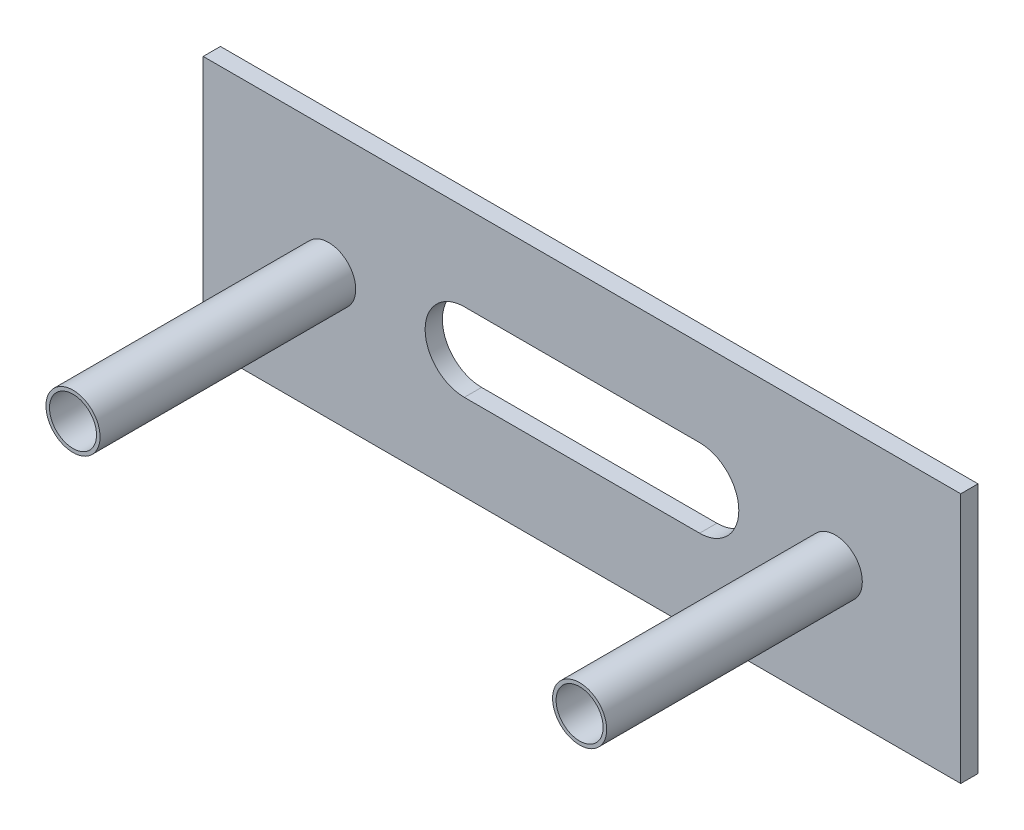
from build123d import *

# Parameters (mm, degrees)
ESQUISSE1_W             = 96.6
ESQUISSE1_H             = 32
BOSS_EXTRU_1_DEPTH      = 2.2
ESQUISSE6_R             = 3.45
BOSS_EXTRU_2_DEPTH      = 32.6
ESQUISSE7_R             = 3
ENL_V_MAT_EXTRU_1_DEPTH = 35.8


with BuildPart() as part:
    # Esquisse1 → Boss.-Extru.1 (new body)
    with BuildSketch(Plane.XY):
        with Locations((0.671156739, 2.259938231)):
            Rectangle(ESQUISSE1_W, ESQUISSE1_H)
    extrude(amount=BOSS_EXTRU_1_DEPTH)

    # Esquisse6 → Boss.-Extru.2 (add)
    with BuildSketch(Plane.XY.offset(2.2)):
        with Locations((-31.628843261, 2.259938231)):
            Circle(ESQUISSE6_R)
        with Locations((32.971156739, 2.259938231)):
            Circle(ESQUISSE6_R)
    extrude(amount=BOSS_EXTRU_2_DEPTH)

    # Esquisse7 → Enlèv. mat.-Extru.1 (cut, through all)
    with BuildSketch(Plane.XY.offset(34.8)):
        with Locations((-31.628843261, 2.259938231)):
            Circle(ESQUISSE7_R)
        with Locations((32.971156739, 2.259938231)):
            Circle(ESQUISSE7_R)
        with BuildLine():
            Line((-14.328843261, 7.259938231), (15.671156739, 7.259938231))
            ThreePointArc((15.671156739, 7.259938231), (20.671156739, 2.259938231), (15.671156739, -2.740061769))
            Line((15.671156739, -2.740061769), (-14.328843261, -2.740061769))
            ThreePointArc((-14.328843261, -2.740061769), (-19.328843261, 2.259938231), (-14.328843261, 7.259938231))
        make_face()
    extrude(amount=-ENL_V_MAT_EXTRU_1_DEPTH, mode=Mode.SUBTRACT)


solid = part.part
